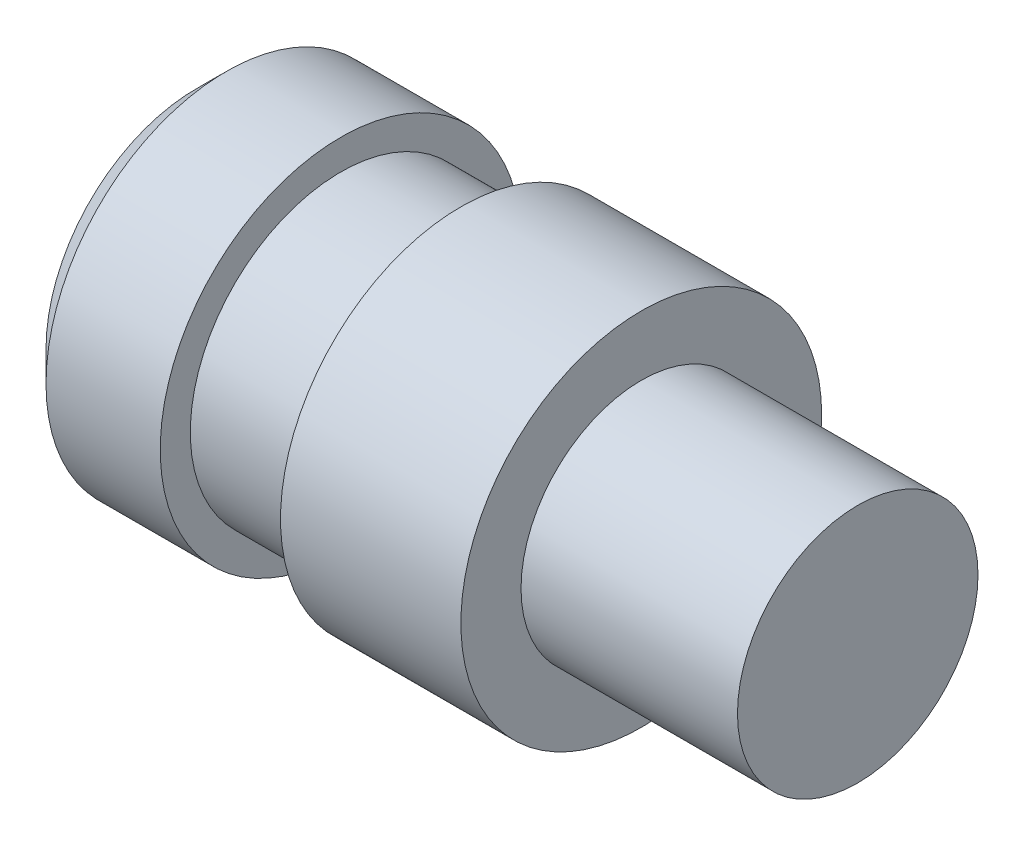
from build123d import *

# Parameters (mm, degrees)
CHANFREIN1_SIZE = 0.5


with BuildPart() as part:
    # Esquisse1 → Révolution1 (revolve)
    with BuildSketch(Plane.XY):
        Polygon((0, 0), (0, 3), (2.4, 3), (2.4, 2.5), (4.4, 2.5), (4.4, 3), (7.4, 3), (7.4, 2), (11, 2), (11, 0), align=None)
    revolve(axis=Axis((11, 0, 0), (-1, 0, 0)))

    # Chanfrein1
    chanfrein1_edges = [part.edges().sort_by_distance(p)[0] for p in [
        (0, -3, 0),
    ]]
    chamfer(chanfrein1_edges, length=CHANFREIN1_SIZE)


solid = part.part
